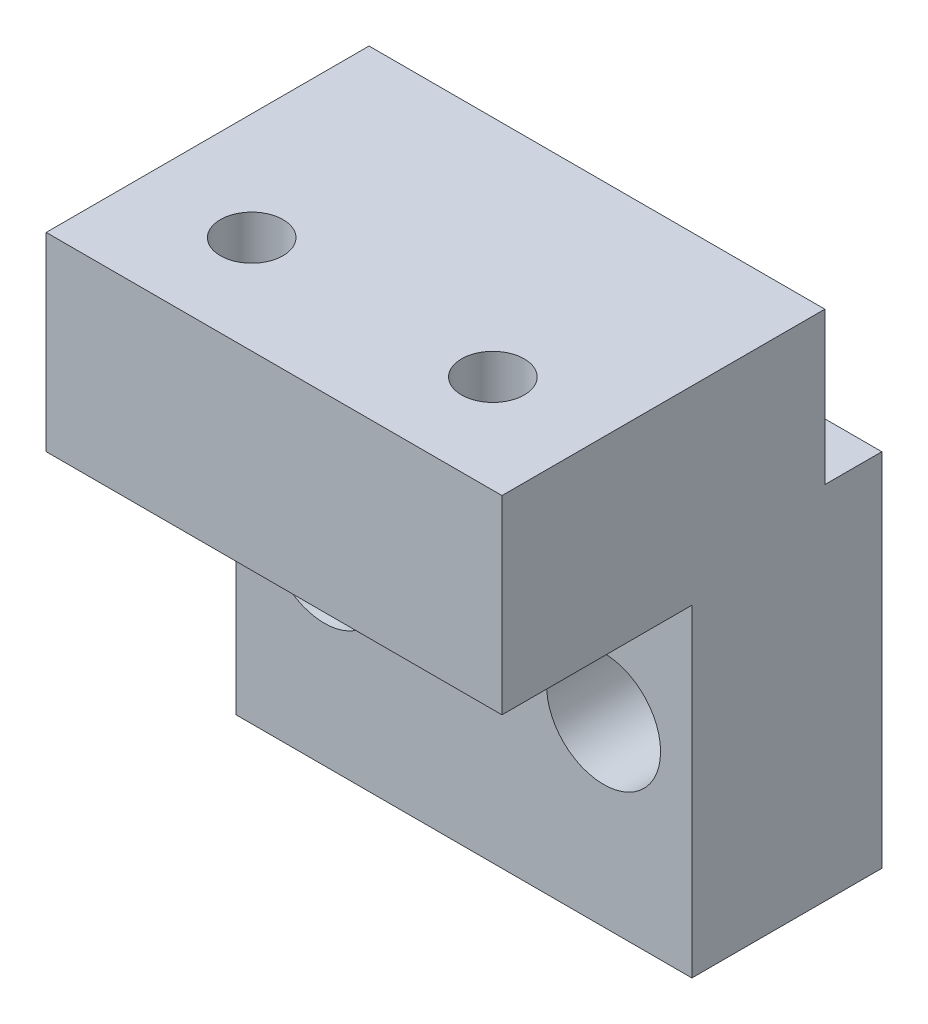
from build123d import *

# Parameters (mm, degrees)
SKETCH1_W           = 24
SKETCH1_H           = 19
SKETCH1_R           = 1.65
BOSS_EXTRUDE1_DEPTH = 10
SKETCH2_R           = 3
CUT_EXTRUDE1_DEPTH  = 5.5
SKETCH4_W           = 24
SKETCH4_H           = 7
BOSS_EXTRUDE2_DEPTH = 8
SKETCH6_W           = 24
SKETCH6_H           = 10
BOSS_EXTRUDE3_DEPTH = 10
SKETCH7_R           = 1.65
CUT_EXTRUDE2_DEPTH  = 28
CUT_EXTRUDE3_DEPTH  = 2.2


with BuildPart() as part:
    # Sketch1 → Boss-Extrude1 (new body)
    with BuildSketch(Plane.XY):
        with Locations((-12, 37.5)):
            Rectangle(SKETCH1_W, SKETCH1_H)
        with Locations((-19.35, 37.5)):
            Circle(SKETCH1_R, mode=Mode.SUBTRACT)
        with Locations((-4.65, 37.5)):
            Circle(SKETCH1_R, mode=Mode.SUBTRACT)
    extrude(amount=BOSS_EXTRUDE1_DEPTH)

    # Sketch2 → Cut-Extrude1 (cut)
    with BuildSketch(Plane.XY.offset(10)):
        with Locations((-4.65, 37.5)):
            Circle(SKETCH2_R)
        with Locations((-19.35, 37.5)):
            Circle(SKETCH2_R)
    extrude(amount=-CUT_EXTRUDE1_DEPTH, mode=Mode.SUBTRACT)

    # Sketch4 → Boss-Extrude2 (add)
    with BuildSketch(Plane(origin=(0, 47, 0), x_dir=(1, 0, 0), z_dir=(0, 1, 0))):
        with Locations((-12, -6.5)):
            Rectangle(SKETCH4_W, SKETCH4_H)
    extrude(amount=BOSS_EXTRUDE2_DEPTH)

    # Sketch6 → Boss-Extrude3 (add)
    with BuildSketch(Plane.XY.offset(10)):
        with Locations((-12, 50)):
            Rectangle(SKETCH6_W, SKETCH6_H)
    extrude(amount=BOSS_EXTRUDE3_DEPTH)

    # Sketch7 → Cut-Extrude2 (cut, through all)
    with BuildSketch(Plane(origin=(0, 55, 0), x_dir=(1, 0, 0), z_dir=(0, 1, 0))):
        with Locations((-5.65, -14.829504021)):
            Circle(SKETCH7_R)
        with Locations((-18.35, -14.829504021)):
            Circle(SKETCH7_R)
    extrude(amount=-CUT_EXTRUDE2_DEPTH, mode=Mode.SUBTRACT)

    # Sketch8 → Cut-Extrude3 (cut)
    with BuildSketch(Plane.XZ.offset(-45)):
        Polygon((-2.359103466, 14.829504021), (-4.004551733, 17.679504021), (-7.295448267, 17.679504021), (-8.940896534, 14.829504021), (-7.295448267, 11.979504021), (-4.004551733, 11.979504021), align=None)
        Polygon((-15.059103466, 14.829504021), (-16.704551733, 17.679504021), (-19.995448267, 17.679504021), (-21.640896534, 14.829504021), (-19.995448267, 11.979504021), (-16.704551733, 11.979504021), align=None)
    extrude(amount=-CUT_EXTRUDE3_DEPTH, mode=Mode.SUBTRACT)


solid = part.part
